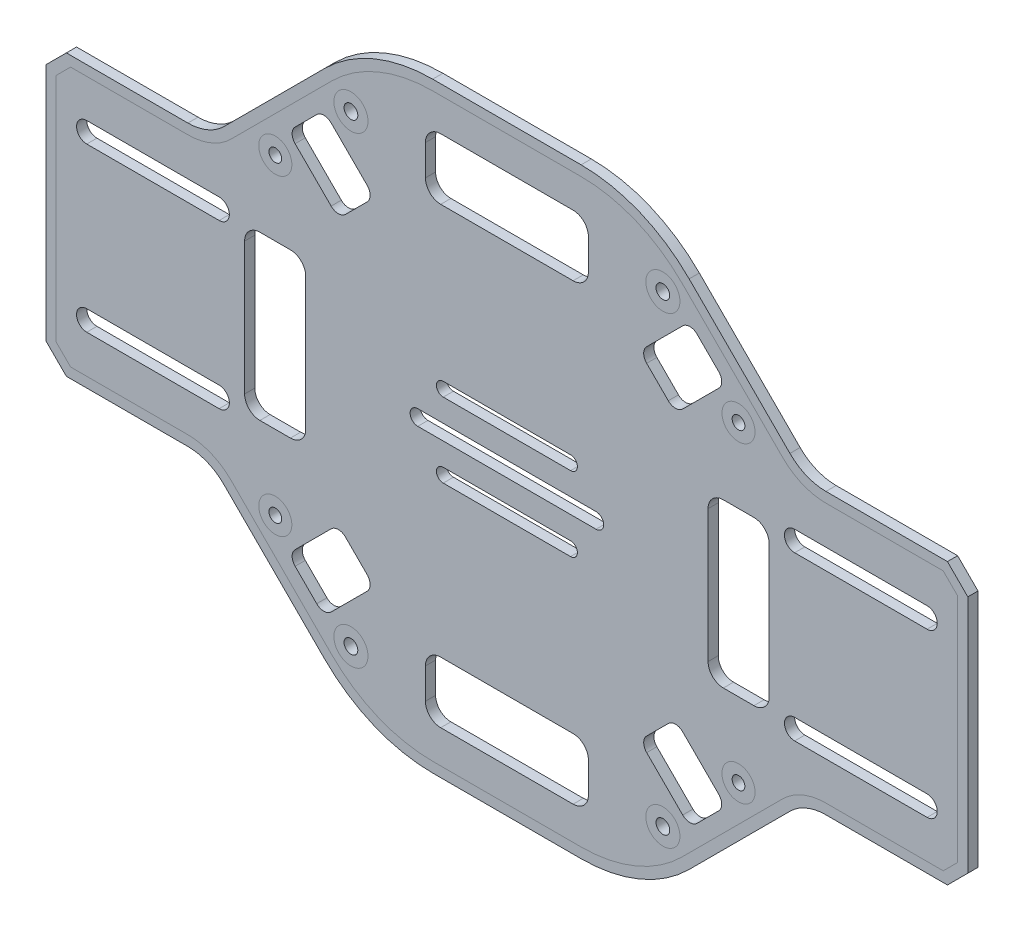
from build123d import *

# Parameters (mm, degrees)
IZIM1_R                     = 1.35
IZIM1_R_2                   = 1.25
Y_KSEKLIK_EKSTR_ZYON1_DEPTH = 2


with BuildPart() as part:
    # Çizim1 → Yükseklik-Ekstrüzyon1 (new body)
    with BuildSketch(Plane.XY):
        with BuildLine():
            Line((90.5, -23.5), (90.5, 23.5))
            Line((90.5, 23.5), (86.5, 27.5))
            Line((86.5, 27.5), (62.642135624, 27.5))
            ThreePointArc((62.642135624, 27.5), (58.8153013, 28.261204675), (55.571067812, 30.428932188))
            Line((55.571067812, 30.428932188), (35.786796564, 50.213203436))
            ThreePointArc((35.786796564, 50.213203436), (26.0540961, 56.716385975), (14.573593129, 59))
            Line((14.573593129, 59), (-14.573593129, 59))
            ThreePointArc((-14.573593129, 59), (-26.0540961, 56.716385975), (-35.786796564, 50.213203436))
            Line((-35.786796564, 50.213203436), (-55.571067812, 30.428932188))
            ThreePointArc((-55.571067812, 30.428932188), (-58.8153013, 28.261204675), (-62.642135624, 27.5))
            Line((-62.642135624, 27.5), (-86.5, 27.5))
            Line((-86.5, 27.5), (-90.5, 23.5))
            Line((-90.5, 23.5), (-90.5, -23.5))
            Line((-90.5, -23.5), (-86.5, -27.5))
            Line((-86.5, -27.5), (-62.642135624, -27.5))
            ThreePointArc((-62.642135624, -27.5), (-58.8153013, -28.261204675), (-55.571067812, -30.428932188))
            Line((-55.571067812, -30.428932188), (-35.786796564, -50.213203436))
            ThreePointArc((-35.786796564, -50.213203436), (-26.0540961, -56.716385975), (-14.573593129, -59))
            Line((-14.573593129, -59), (14.573593129, -59))
            ThreePointArc((14.573593129, -59), (26.0540961, -56.716385975), (35.786796564, -50.213203436))
            Line((35.786796564, -50.213203436), (55.571067812, -30.428932188))
            ThreePointArc((55.571067812, -30.428932188), (58.8153013, -28.261204675), (62.642135624, -27.5))
            Line((62.642135624, -27.5), (86.5, -27.5))
            Line((86.5, -27.5), (90.5, -23.5))
        make_face()
        with Locations((-30.625631329, 45.474873734)):
            Circle(IZIM1_R, mode=Mode.SUBTRACT)
        with Locations((-45.474873734, 30.625631329)):
            Circle(IZIM1_R_2, mode=Mode.SUBTRACT)
        with Locations((45.474873734, 30.625631329)):
            Circle(IZIM1_R_2, mode=Mode.SUBTRACT)
        with Locations((30.625631329, 45.474873734)):
            Circle(IZIM1_R, mode=Mode.SUBTRACT)
        with Locations((-45.474873734, -30.625631329)):
            Circle(IZIM1_R_2, mode=Mode.SUBTRACT)
        with Locations((-30.625631329, -45.474873734)):
            Circle(IZIM1_R, mode=Mode.SUBTRACT)
        with Locations((30.625631329, -45.474873734)):
            Circle(IZIM1_R, mode=Mode.SUBTRACT)
        with Locations((45.474873734, -30.625631329)):
            Circle(IZIM1_R_2, mode=Mode.SUBTRACT)
        with BuildLine():
            Line((-82.5, -14), (-56.5, -14))
            ThreePointArc((-56.5, -14), (-54.5, -16), (-56.5, -18))
            Line((-56.5, -18), (-82.5, -18))
            ThreePointArc((-82.5, -18), (-84.5, -16), (-82.5, -14))
        make_face(mode=Mode.SUBTRACT)
        with BuildLine():
            Line((-12.5, -5.968164753), (12.5, -5.968164753))
            ThreePointArc((12.5, -5.968164753), (13.842447595, -7.310612349), (12.5, -8.653059944))
            Line((12.5, -8.653059944), (-12.5, -8.653059944))
            ThreePointArc((-12.5, -8.653059944), (-13.842447595, -7.310612349), (-12.5, -5.968164753))
        make_face(mode=Mode.SUBTRACT)
        with BuildLine():
            Line((-37.343145751, -41.585786438), (-41.585786438, -37.343145751))
            ThreePointArc((-41.585786438, -37.343145751), (-42.171572875, -35.928932188), (-41.585786438, -34.514718626))
            Line((-41.585786438, -34.514718626), (-34.514718626, -27.443650814))
            ThreePointArc((-34.514718626, -27.443650814), (-33.100505063, -26.857864376), (-31.686291501, -27.443650814))
            Line((-31.686291501, -27.443650814), (-27.443650814, -31.686291501))
            ThreePointArc((-27.443650814, -31.686291501), (-26.857864376, -33.100505063), (-27.443650814, -34.514718626))
            Line((-27.443650814, -34.514718626), (-34.514718626, -41.585786438))
            ThreePointArc((-34.514718626, -41.585786438), (-35.928932188, -42.171572875), (-37.343145751, -41.585786438))
        make_face(mode=Mode.SUBTRACT)
        with BuildLine():
            Line((-12.5, 5.968164753), (12.5, 5.968164753))
            ThreePointArc((12.5, 5.968164753), (13.842447595, 7.310612349), (12.5, 8.653059944))
            Line((12.5, 8.653059944), (-12.5, 8.653059944))
            ThreePointArc((-12.5, 8.653059944), (-13.842447595, 7.310612349), (-12.5, 5.968164753))
        make_face(mode=Mode.SUBTRACT)
        with BuildLine():
            Line((0, -50.5), (13, -50.5))
            ThreePointArc((13, -50.5), (15.121320344, -49.621320344), (16, -47.5))
            Line((16, -47.5), (16, -41.5))
            ThreePointArc((16, -41.5), (15.121320344, -39.378679656), (13, -38.5))
            Line((13, -38.5), (-13, -38.5))
            ThreePointArc((-13, -38.5), (-15.121320344, -39.378679656), (-16, -41.5))
            Line((-16, -41.5), (-16, -47.5))
            ThreePointArc((-16, -47.5), (-15.121320344, -49.621320344), (-13, -50.5))
            Line((-13, -50.5), (0, -50.5))
        make_face(mode=Mode.SUBTRACT)
        with BuildLine():
            Line((-17.5, 1.5), (17.5, 1.5))
            ThreePointArc((17.5, 1.5), (19, 0), (17.5, -1.5))
            Line((17.5, -1.5), (-17.5, -1.5))
            ThreePointArc((-17.5, -1.5), (-19, 0), (-17.5, 1.5))
        make_face(mode=Mode.SUBTRACT)
        with BuildLine():
            Line((-82.5, 14), (-56.5, 14))
            ThreePointArc((-56.5, 14), (-54.5, 16), (-56.5, 18))
            Line((-56.5, 18), (-82.5, 18))
            ThreePointArc((-82.5, 18), (-84.5, 16), (-82.5, 14))
        make_face(mode=Mode.SUBTRACT)
        with BuildLine():
            Line((16, 47.5), (16, 41.5))
            ThreePointArc((16, 41.5), (15.121320344, 39.378679656), (13, 38.5))
            Line((13, 38.5), (-13, 38.5))
            ThreePointArc((-13, 38.5), (-15.121320344, 39.378679656), (-16, 41.5))
            Line((-16, 41.5), (-16, 47.5))
            ThreePointArc((-16, 47.5), (-15.121320344, 49.621320344), (-13, 50.5))
            Line((-13, 50.5), (0, 50.5))
            Line((0, 50.5), (13, 50.5))
            ThreePointArc((13, 50.5), (15.121320344, 49.621320344), (16, 47.5))
        make_face(mode=Mode.SUBTRACT)
        with BuildLine():
            Line((-34.514718626, 41.585786438), (-27.443650814, 34.514718626))
            ThreePointArc((-27.443650814, 34.514718626), (-26.857864376, 33.100505063), (-27.443650814, 31.686291501))
            Line((-27.443650814, 31.686291501), (-31.686291501, 27.443650814))
            ThreePointArc((-31.686291501, 27.443650814), (-33.100505063, 26.857864376), (-34.514718626, 27.443650814))
            Line((-34.514718626, 27.443650814), (-41.585786438, 34.514718626))
            ThreePointArc((-41.585786438, 34.514718626), (-42.171572875, 35.928932188), (-41.585786438, 37.343145751))
            Line((-41.585786438, 37.343145751), (-37.343145751, 41.585786438))
            ThreePointArc((-37.343145751, 41.585786438), (-35.928932188, 42.171572875), (-34.514718626, 41.585786438))
        make_face(mode=Mode.SUBTRACT)
        with BuildLine():
            Line((82.5, -14), (56.5, -14))
            ThreePointArc((56.5, -14), (54.5, -16), (56.5, -18))
            Line((56.5, -18), (82.5, -18))
            ThreePointArc((82.5, -18), (84.5, -16), (82.5, -14))
        make_face(mode=Mode.SUBTRACT)
        with BuildLine():
            Line((82.5, 14), (56.5, 14))
            ThreePointArc((56.5, 14), (54.5, 16), (56.5, 18))
            Line((56.5, 18), (82.5, 18))
            ThreePointArc((82.5, 18), (84.5, 16), (82.5, 14))
        make_face(mode=Mode.SUBTRACT)
        with BuildLine():
            Line((34.514718626, -41.585786438), (27.443650814, -34.514718626))
            ThreePointArc((27.443650814, -34.514718626), (26.857864376, -33.100505063), (27.443650814, -31.686291501))
            Line((27.443650814, -31.686291501), (31.686291501, -27.443650814))
            ThreePointArc((31.686291501, -27.443650814), (33.100505063, -26.857864376), (34.514718626, -27.443650814))
            Line((34.514718626, -27.443650814), (41.585786438, -34.514718626))
            ThreePointArc((41.585786438, -34.514718626), (42.171572875, -35.928932188), (41.585786438, -37.343145751))
            Line((41.585786438, -37.343145751), (37.343145751, -41.585786438))
            ThreePointArc((37.343145751, -41.585786438), (35.928932188, -42.171572875), (34.514718626, -41.585786438))
        make_face(mode=Mode.SUBTRACT)
        with BuildLine():
            Line((37.343145751, 41.585786438), (41.585786438, 37.343145751))
            ThreePointArc((41.585786438, 37.343145751), (42.171572875, 35.928932188), (41.585786438, 34.514718626))
            Line((41.585786438, 34.514718626), (34.514718626, 27.443650814))
            ThreePointArc((34.514718626, 27.443650814), (33.100505063, 26.857864376), (31.686291501, 27.443650814))
            Line((31.686291501, 27.443650814), (27.443650814, 31.686291501))
            ThreePointArc((27.443650814, 31.686291501), (26.857864376, 33.100505063), (27.443650814, 34.514718626))
            Line((27.443650814, 34.514718626), (34.514718626, 41.585786438))
            ThreePointArc((34.514718626, 41.585786438), (35.928932188, 42.171572875), (37.343145751, 41.585786438))
        make_face(mode=Mode.SUBTRACT)
        with BuildLine():
            Line((-51.5, 0), (-51.5, -13))
            ThreePointArc((-51.5, -13), (-50.621320344, -15.121320344), (-48.5, -16))
            Line((-48.5, -16), (-42.5, -16))
            ThreePointArc((-42.5, -16), (-40.378679656, -15.121320344), (-39.5, -13))
            Line((-39.5, -13), (-39.5, 13))
            ThreePointArc((-39.5, 13), (-40.378679656, 15.121320344), (-42.5, 16))
            Line((-42.5, 16), (-48.5, 16))
            ThreePointArc((-48.5, 16), (-50.621320344, 15.121320344), (-51.5, 13))
            Line((-51.5, 13), (-51.5, 0))
        make_face(mode=Mode.SUBTRACT)
        with BuildLine():
            Line((51.5, 13), (51.5, 0))
            Line((51.5, 0), (51.5, -13))
            ThreePointArc((51.5, -13), (50.621320344, -15.121320344), (48.5, -16))
            Line((48.5, -16), (42.5, -16))
            ThreePointArc((42.5, -16), (40.378679656, -15.121320344), (39.5, -13))
            Line((39.5, -13), (39.5, 13))
            ThreePointArc((39.5, 13), (40.378679656, 15.121320344), (42.5, 16))
            Line((42.5, 16), (48.5, 16))
            ThreePointArc((48.5, 16), (50.621320344, 15.121320344), (51.5, 13))
        make_face(mode=Mode.SUBTRACT)
    extrude(amount=Y_KSEKLIK_EKSTR_ZYON1_DEPTH)


solid = part.part
